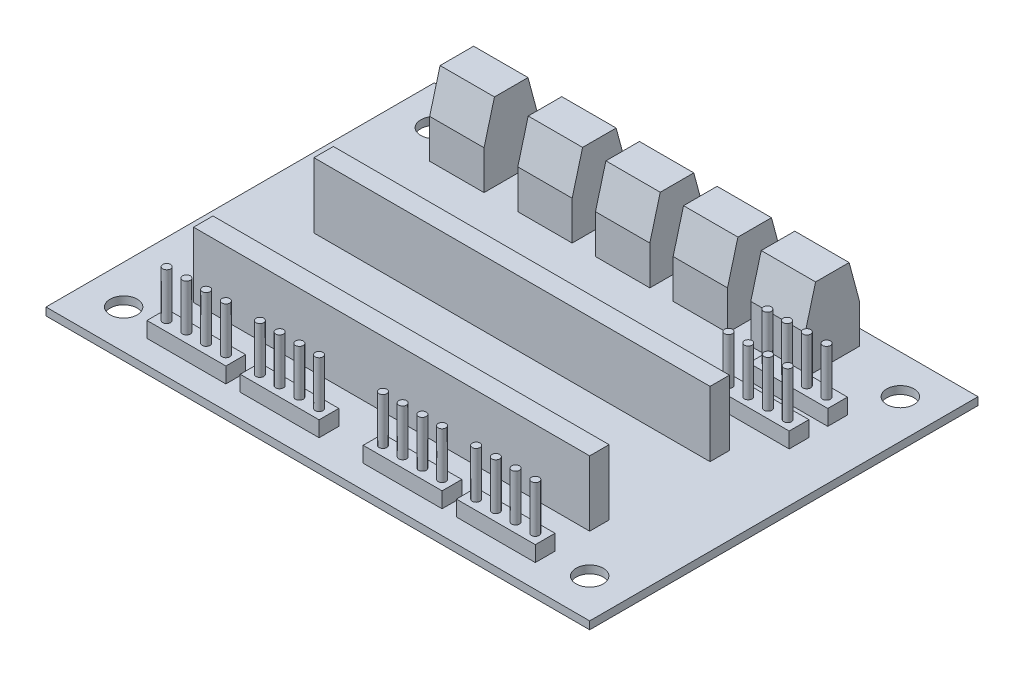
from build123d import *

# Parameters (mm, degrees)
SKETCH_2_W              = 70
SKETCH_2_H              = 50
SKETCH_2_R              = 1.75
EXTRUDE_1_DEPTH         = 1
SKETCH_3_W              = 51
SKETCH_3_H              = 2.5
EXTRUDE_2_DEPTH         = 8.4
SKETCH_4_W              = 10.16
SKETCH_4_H              = 2.54
EXTRUDE_3_DEPTH         = 2
SKETCH_5_R              = 0.5
EXTRUDE_4_DEPTH         = 6
SKETCH_6_W              = 7
SKETCH_6_H              = 7
EXTRUDE_5_DEPTH         = 10
CHAMFER_1_SIZE          = 5
CHAMFER_1_SIZE2         = 1.339745962
CHAMFER_1_PART_2_SIZE   = 5
CHAMFER_1_PART_2_SIZE2  = 1.339745962
CHAMFER_1_PART_3_SIZE   = 5
CHAMFER_1_PART_3_SIZE2  = 1.339745962
CHAMFER_1_PART_4_SIZE   = 5
CHAMFER_1_PART_4_SIZE2  = 1.339745962
CHAMFER_1_PART_5_SIZE   = 5
CHAMFER_1_PART_5_SIZE2  = 1.339745962
CHAMFER_1_PART_6_SIZE   = 5
CHAMFER_1_PART_6_SIZE2  = 1.339745962
CHAMFER_1_PART_7_SIZE   = 5
CHAMFER_1_PART_7_SIZE2  = 1.339745962
CHAMFER_1_PART_8_SIZE   = 5
CHAMFER_1_PART_8_SIZE2  = 1.339745962
CHAMFER_1_PART_9_SIZE   = 5
CHAMFER_1_PART_9_SIZE2  = 1.339745962
CHAMFER_1_PART_10_SIZE  = 5
CHAMFER_1_PART_10_SIZE2 = 1.339745962
CUT_EXTRUDE_START       = 0.046624
SKETCH_7_R              = 1
CUT_EXTRUDE_1_DEPTH     = 2


with BuildPart() as part:
    # Эскиз2 → Бобышка-Вытянуть1 (new body)
    with BuildSketch(Plane(origin=(0, 0, 0), x_dir=(1, 0, 0), z_dir=(0, 1, 0))):
        with Locations((35, 25)):
            Rectangle(SKETCH_2_W, SKETCH_2_H)
        with Locations((5, 45)):
            Circle(SKETCH_2_R, mode=Mode.SUBTRACT)
        with Locations((65, 45)):
            Circle(SKETCH_2_R, mode=Mode.SUBTRACT)
        with Locations((65, 5)):
            Circle(SKETCH_2_R, mode=Mode.SUBTRACT)
        with Locations((5, 5)):
            Circle(SKETCH_2_R, mode=Mode.SUBTRACT)
    extrude(amount=EXTRUDE_1_DEPTH)

    # Эскиз3 → Бобышка-Вытянуть2 (add)
    with BuildSketch(Plane(origin=(0, 1, 0), x_dir=(1, 0, 0), z_dir=(0, 1, 0))):
        with Locations((34.5, 11.25)):
            Rectangle(SKETCH_3_W, SKETCH_3_H)
        with Locations((34.5, 26.75)):
            Rectangle(SKETCH_3_W, SKETCH_3_H)
    extrude(amount=EXTRUDE_2_DEPTH)

    # Эскиз4 → Бобышка-Вытянуть3 (add)
    with BuildSketch(Plane(origin=(0, 1, 0), x_dir=(1, 0, 0), z_dir=(0, 1, 0))):
        with Locations((54.92, 4.27)):
            Rectangle(SKETCH_4_W, SKETCH_4_H)
        with Locations((42.92, 4.27)):
            Rectangle(SKETCH_4_W, SKETCH_4_H)
        with Locations((15.08, 4.27)):
            Rectangle(SKETCH_4_W, SKETCH_4_H)
        with Locations((27.08, 4.27)):
            Rectangle(SKETCH_4_W, SKETCH_4_H)
        with Locations((58.562253528, 38.283187026)):
            Rectangle(SKETCH_4_W, SKETCH_4_H)
        with Locations((58.594566993, 33.283187026)):
            Rectangle(SKETCH_4_W, SKETCH_4_H)
    extrude(amount=EXTRUDE_3_DEPTH)

    # Эскиз5 → Бобышка-Вытянуть4 (add)
    with BuildSketch(Plane(origin=(0, 3, 0), x_dir=(1, 0, 0), z_dir=(0, 1, 0))):
        with Locations((58.73, 4.27)):
            Circle(SKETCH_5_R)
        with Locations((56.19, 4.27)):
            Circle(SKETCH_5_R)
        with Locations((53.65, 4.27)):
            Circle(SKETCH_5_R)
        with Locations((51.11, 4.27)):
            Circle(SKETCH_5_R)
        with Locations((46.73, 4.27)):
            Circle(SKETCH_5_R)
        with Locations((44.19, 4.27)):
            Circle(SKETCH_5_R)
        with Locations((41.65, 4.27)):
            Circle(SKETCH_5_R)
        with Locations((39.11, 4.27)):
            Circle(SKETCH_5_R)
        with Locations((25.81, 4.27)):
            Circle(SKETCH_5_R)
        with Locations((11.27, 4.27)):
            Circle(SKETCH_5_R)
        with Locations((13.81, 4.27)):
            Circle(SKETCH_5_R)
        with Locations((16.35, 4.27)):
            Circle(SKETCH_5_R)
        with Locations((18.89, 4.27)):
            Circle(SKETCH_5_R)
        with Locations((23.27, 4.27)):
            Circle(SKETCH_5_R)
        with Locations((28.35, 4.27)):
            Circle(SKETCH_5_R)
        with Locations((30.89, 4.27)):
            Circle(SKETCH_5_R)
        with Locations((54.67096141, 33.208395661)):
            Circle(SKETCH_5_R)
        with Locations((54.67096141, 38.208395661)):
            Circle(SKETCH_5_R)
        with Locations((57.21096141, 33.208395661)):
            Circle(SKETCH_5_R)
        with Locations((59.75096141, 33.208395661)):
            Circle(SKETCH_5_R)
        with Locations((62.29096141, 33.208395661)):
            Circle(SKETCH_5_R)
        with Locations((57.21096141, 38.208395661)):
            Circle(SKETCH_5_R)
        with Locations((59.75096141, 38.208395661)):
            Circle(SKETCH_5_R)
        with Locations((62.29096141, 38.208395661)):
            Circle(SKETCH_5_R)
    extrude(amount=EXTRUDE_4_DEPTH)

    # Эскиз6 → Бобышка-Вытянуть5 (add)
    with BuildSketch(Plane(origin=(0, 1, 0), x_dir=(1, 0, 0), z_dir=(0, 1, 0))):
        with Locations((23.247184381, 44.500218353)):
            Rectangle(SKETCH_6_W, SKETCH_6_H)
        with Locations((11.946306787, 44.453594358)):
            Rectangle(SKETCH_6_W, SKETCH_6_H)
        with Locations((33.247184381, 44.500218353)):
            Rectangle(SKETCH_6_W, SKETCH_6_H)
        with Locations((43.247184381, 44.500218353)):
            Rectangle(SKETCH_6_W, SKETCH_6_H)
        with Locations((53.247184381, 44.500218353)):
            Rectangle(SKETCH_6_W, SKETCH_6_H)
    extrude(amount=EXTRUDE_5_DEPTH)

    # Фаска1
    chamfer_1_edges = [part.edges().sort_by_distance(p)[0] for p in [
        (23.247184381, 11, -41.000218353),
    ]]
    chamfer_1_side = [part.faces().sort_by_distance(p)[0] for p in [
        (23.247184381, 6, -41.000218353),
    ]]
    chamfer(chamfer_1_edges, length=CHAMFER_1_SIZE, length2=CHAMFER_1_SIZE2, reference=chamfer_1_side[0])

    # Фаска1 part 2
    chamfer_1_part_2_edges = [part.edges().sort_by_distance(p)[0] for p in [
        (23.247184381, 11, -48.000218353),
    ]]
    chamfer_1_part_2_side = [part.faces().sort_by_distance(p)[0] for p in [
        (23.247184381, 6, -48.000218353),
    ]]
    chamfer(chamfer_1_part_2_edges, length=CHAMFER_1_PART_2_SIZE, length2=CHAMFER_1_PART_2_SIZE2, reference=chamfer_1_part_2_side[0])

    # Фаска1 part 3
    chamfer_1_part_3_edges = [part.edges().sort_by_distance(p)[0] for p in [
        (11.946306787, 11, -40.953594358),
    ]]
    chamfer_1_part_3_side = [part.faces().sort_by_distance(p)[0] for p in [
        (11.946306787, 6, -40.953594358),
    ]]
    chamfer(chamfer_1_part_3_edges, length=CHAMFER_1_PART_3_SIZE, length2=CHAMFER_1_PART_3_SIZE2, reference=chamfer_1_part_3_side[0])

    # Фаска1 part 4
    chamfer_1_part_4_edges = [part.edges().sort_by_distance(p)[0] for p in [
        (11.946306787, 11, -47.953594358),
    ]]
    chamfer_1_part_4_side = [part.faces().sort_by_distance(p)[0] for p in [
        (11.946306787, 6, -47.953594358),
    ]]
    chamfer(chamfer_1_part_4_edges, length=CHAMFER_1_PART_4_SIZE, length2=CHAMFER_1_PART_4_SIZE2, reference=chamfer_1_part_4_side[0])

    # Фаска1 part 5
    chamfer_1_part_5_edges = [part.edges().sort_by_distance(p)[0] for p in [
        (33.247184381, 11, -41.000218353),
    ]]
    chamfer_1_part_5_side = [part.faces().sort_by_distance(p)[0] for p in [
        (33.247184381, 6, -41.000218353),
    ]]
    chamfer(chamfer_1_part_5_edges, length=CHAMFER_1_PART_5_SIZE, length2=CHAMFER_1_PART_5_SIZE2, reference=chamfer_1_part_5_side[0])

    # Фаска1 part 6
    chamfer_1_part_6_edges = [part.edges().sort_by_distance(p)[0] for p in [
        (33.247184381, 11, -48.000218353),
    ]]
    chamfer_1_part_6_side = [part.faces().sort_by_distance(p)[0] for p in [
        (33.247184381, 6, -48.000218353),
    ]]
    chamfer(chamfer_1_part_6_edges, length=CHAMFER_1_PART_6_SIZE, length2=CHAMFER_1_PART_6_SIZE2, reference=chamfer_1_part_6_side[0])

    # Фаска1 part 7
    chamfer_1_part_7_edges = [part.edges().sort_by_distance(p)[0] for p in [
        (43.247184381, 11, -41.000218353),
    ]]
    chamfer_1_part_7_side = [part.faces().sort_by_distance(p)[0] for p in [
        (43.247184381, 6, -41.000218353),
    ]]
    chamfer(chamfer_1_part_7_edges, length=CHAMFER_1_PART_7_SIZE, length2=CHAMFER_1_PART_7_SIZE2, reference=chamfer_1_part_7_side[0])

    # Фаска1 part 8
    chamfer_1_part_8_edges = [part.edges().sort_by_distance(p)[0] for p in [
        (43.247184381, 11, -48.000218353),
    ]]
    chamfer_1_part_8_side = [part.faces().sort_by_distance(p)[0] for p in [
        (43.247184381, 6, -48.000218353),
    ]]
    chamfer(chamfer_1_part_8_edges, length=CHAMFER_1_PART_8_SIZE, length2=CHAMFER_1_PART_8_SIZE2, reference=chamfer_1_part_8_side[0])

    # Фаска1 part 9
    chamfer_1_part_9_edges = [part.edges().sort_by_distance(p)[0] for p in [
        (53.247184381, 11, -41.000218353),
    ]]
    chamfer_1_part_9_side = [part.faces().sort_by_distance(p)[0] for p in [
        (53.247184381, 6, -41.000218353),
    ]]
    chamfer(chamfer_1_part_9_edges, length=CHAMFER_1_PART_9_SIZE, length2=CHAMFER_1_PART_9_SIZE2, reference=chamfer_1_part_9_side[0])

    # Фаска1 part 10
    chamfer_1_part_10_edges = [part.edges().sort_by_distance(p)[0] for p in [
        (53.247184381, 11, -48.000218353),
    ]]
    chamfer_1_part_10_side = [part.faces().sort_by_distance(p)[0] for p in [
        (53.247184381, 6, -48.000218353),
    ]]
    chamfer(chamfer_1_part_10_edges, length=CHAMFER_1_PART_10_SIZE, length2=CHAMFER_1_PART_10_SIZE2, reference=chamfer_1_part_10_side[0])

    # Эскиз7 → Вырез-Вытянуть1 (cut)
    with BuildSketch(Plane(origin=(0, 0, -47.953594358), x_dir=(-1, 0, 0), z_dir=(0, 0, -1)).offset(CUT_EXTRUDE_START)):
        with Locations((-10.259866322, 3.21835238)):
            Circle(SKETCH_7_R)
        with Locations((-13.281229876, 3.21835238)):
            Circle(SKETCH_7_R)
        with Locations((-21.706301123, 3.223335503)):
            Circle(SKETCH_7_R)
        with Locations((-24.727664678, 3.223335503)):
            Circle(SKETCH_7_R)
        with Locations((-34.727664678, 3.223335503)):
            Circle(SKETCH_7_R)
        with Locations((-31.706301123, 3.223335503)):
            Circle(SKETCH_7_R)
        with Locations((-44.727664678, 3.223335503)):
            Circle(SKETCH_7_R)
        with Locations((-41.706301123, 3.223335503)):
            Circle(SKETCH_7_R)
        with Locations((-54.727664678, 3.223335503)):
            Circle(SKETCH_7_R)
        with Locations((-51.706301123, 3.223335503)):
            Circle(SKETCH_7_R)
    extrude(amount=-CUT_EXTRUDE_1_DEPTH, mode=Mode.SUBTRACT)


solid = part.part
